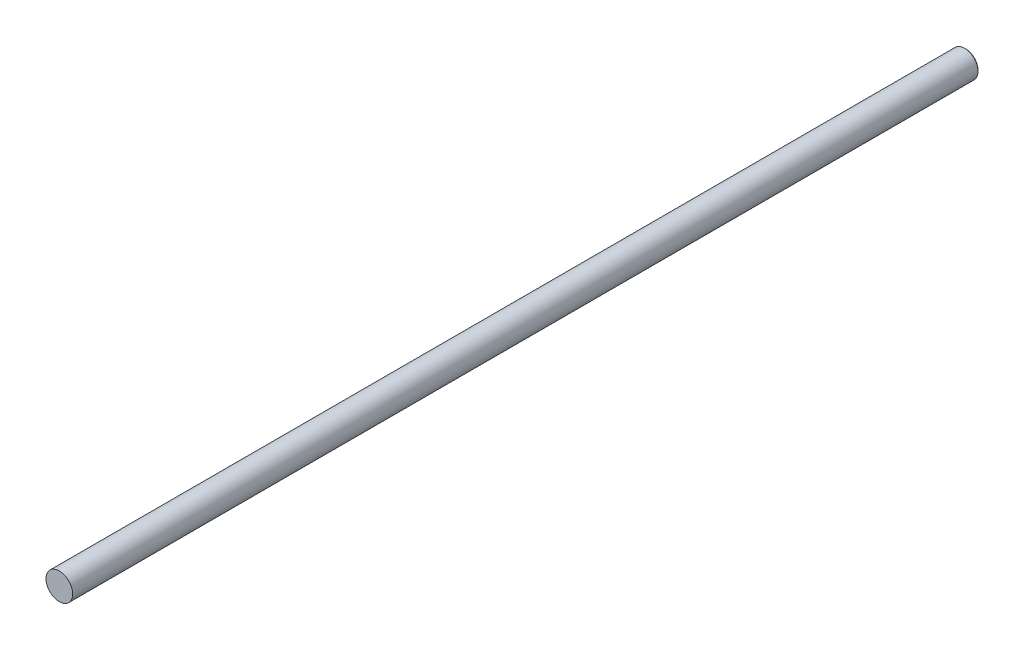
from build123d import *

# Parameters (mm, degrees)
SKETCH1_R          = 3.175
BASE_EXTRUDE_DEPTH = 215.9
CHAMFER1_SIZE      = 0.254


with BuildPart() as part:
    # Sketch1 → Base-Extrude (new body)
    with BuildSketch(Plane.XY):
        Circle(SKETCH1_R)
    extrude(amount=-BASE_EXTRUDE_DEPTH)

    # Chamfer1
    chamfer1_edges = [part.edges().sort_by_distance(p)[0] for p in [
        (-3.175, 0, -215.9),
    ]]
    chamfer(chamfer1_edges, length=CHAMFER1_SIZE)


solid = part.part
